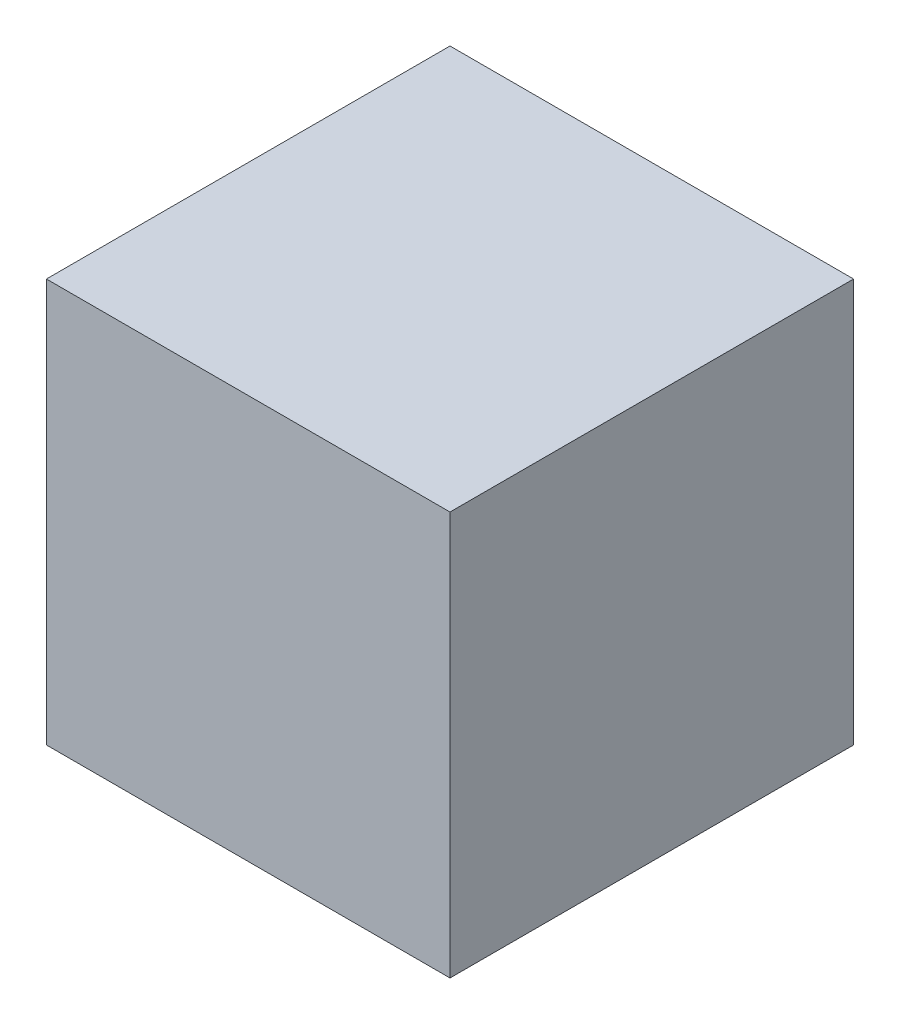
from build123d import *

# Parameters (mm, degrees)
SKETCH_1_W      = 40
SKETCH_1_H      = 40
EXTRUDE_1_DEPTH = 40


with BuildPart() as part:
    # 草图1 → 凸台-拉伸1 (new body)
    with BuildSketch(Plane(origin=(0, 0, 0), x_dir=(1, 0, 0), z_dir=(0, 1, 0))):
        Rectangle(SKETCH_1_W, SKETCH_1_H)
    extrude(amount=EXTRUDE_1_DEPTH)


solid = part.part
